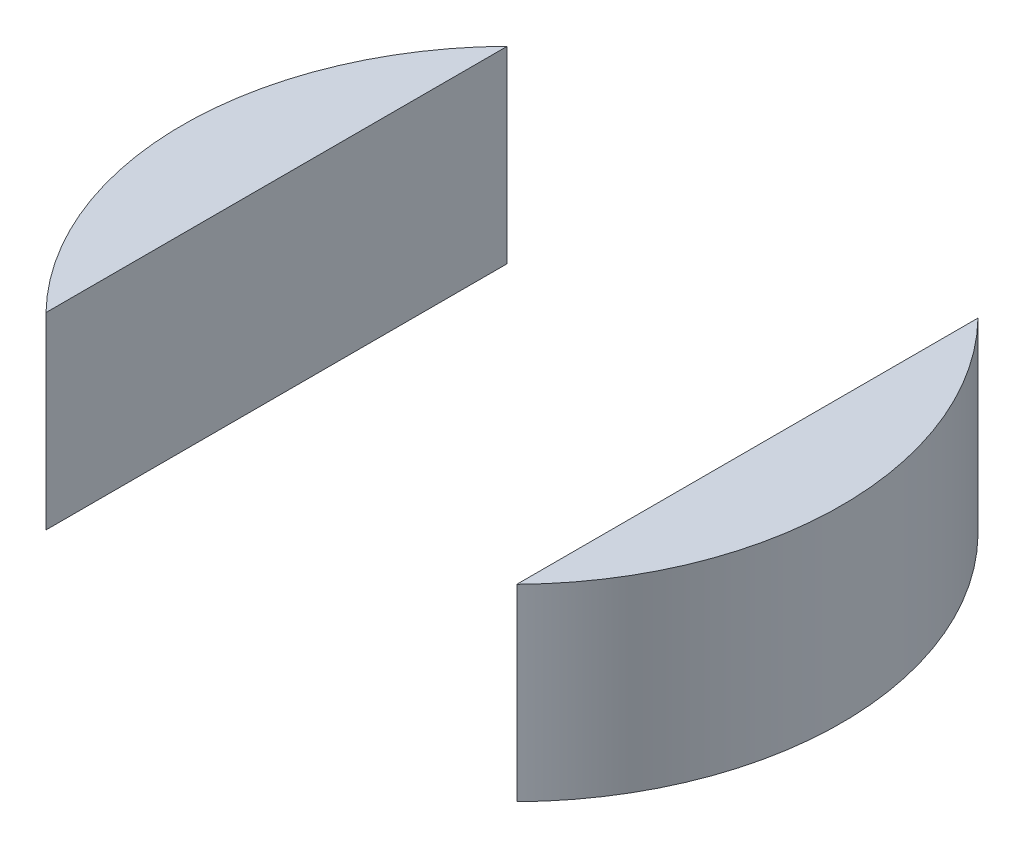
from build123d import *

# Parameters (mm, degrees)
BOSS_EXTRUDE1_DEPTH = 10


with BuildPart() as part:
    # Sketch2 → Boss-Extrude1 (new body)
    with BuildSketch(Plane(origin=(0, 0, 0), x_dir=(1, 0, 0), z_dir=(0, 1, 0))):
        with BuildLine():
            Line((-12.5, 9.987492178), (-12.5, 12.247448714))
            ThreePointArc((-12.5, 12.247448714), (-17.5, 0), (-12.5, -12.247448714))
            Line((-12.5, -12.247448714), (-12.5, -9.987492178))
            ThreePointArc((-12.5, -9.987492178), (-14.92684663, -5.76101117), (-15.968719423, -1))
            ThreePointArc((-15.968719423, -1), (-16, 0), (-15.968719423, 1))
            ThreePointArc((-15.968719423, 1), (-14.92684663, 5.76101117), (-12.5, 9.987492178))
        make_face()
        with BuildLine():
            Line((-12.5, 1), (-12.5, 9.987492178))
            ThreePointArc((-12.5, 9.987492178), (-14.92684663, 5.76101117), (-15.968719423, 1))
            Line((-15.968719423, 1), (-12.5, 1))
        make_face()
        with BuildLine():
            ThreePointArc((-15.968719423, -1), (-14.92684663, -5.76101117), (-12.5, -9.987492178))
            Line((-12.5, -9.987492178), (-12.5, -1))
            Line((-12.5, -1), (-15.968719423, -1))
        make_face()
        with BuildLine():
            Line((-12.5, -1), (-12.5, 1))
            Line((-12.5, 1), (-15.968719423, 1))
            ThreePointArc((-15.968719423, 1), (-16, 0), (-15.968719423, -1))
            Line((-15.968719423, -1), (-12.5, -1))
        make_face()
        with BuildLine():
            ThreePointArc((17.5, 0), (16.201851746, 6.614378278), (12.5, 12.247448714))
            Line((12.5, 12.247448714), (12.5, 9.987492178))
            ThreePointArc((12.5, 9.987492178), (14.92684663, 5.76101117), (15.968719423, 1))
            ThreePointArc((15.968719423, 1), (15.992177944, 0.500244559), (16, 0))
            ThreePointArc((16, 0), (15.992177944, -0.500244559), (15.968719423, -1))
            ThreePointArc((15.968719423, -1), (14.92684663, -5.76101117), (12.5, -9.987492178))
            Line((12.5, -9.987492178), (12.5, -12.247448714))
            ThreePointArc((12.5, -12.247448714), (16.201851746, -6.614378278), (17.5, 0))
        make_face()
        with BuildLine():
            ThreePointArc((15.968719423, 1), (14.92684663, 5.76101117), (12.5, 9.987492178))
            Line((12.5, 9.987492178), (12.5, 1))
            Line((12.5, 1), (15.968719423, 1))
        make_face()
        with BuildLine():
            Line((15.968719423, 1), (12.5, 1))
            Line((12.5, 1), (12.5, -1))
            Line((12.5, -1), (15.968719423, -1))
            ThreePointArc((15.968719423, -1), (15.992177944, -0.500244559), (16, 0))
            ThreePointArc((16, 0), (15.992177944, 0.500244559), (15.968719423, 1))
        make_face()
        with BuildLine():
            Line((12.5, -1), (12.5, -9.987492178))
            ThreePointArc((12.5, -9.987492178), (14.92684663, -5.76101117), (15.968719423, -1))
            Line((15.968719423, -1), (12.5, -1))
        make_face()
    extrude(amount=BOSS_EXTRUDE1_DEPTH)


solid = part.part
